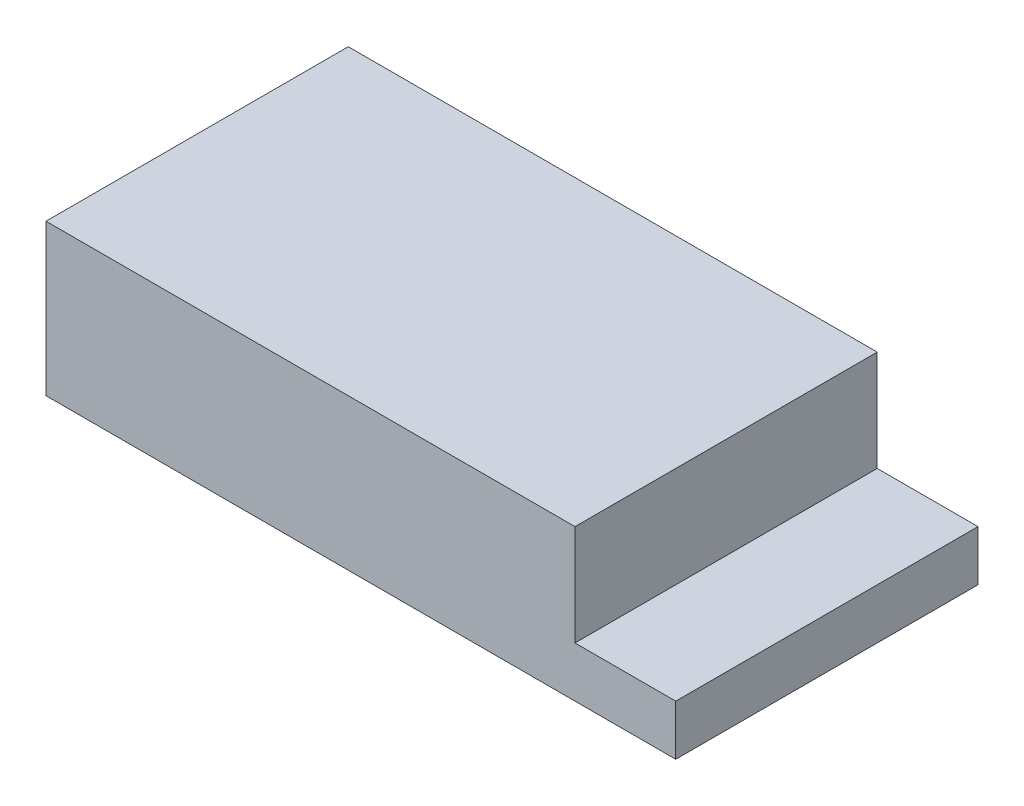
from build123d import *

# Parameters (mm, degrees)
SKETCH1_W           = 125
SKETCH1_H           = 60
BOSS_EXTRUDE1_DEPTH = 30
SKETCH2_W           = 20
SKETCH2_H           = 60
CUT_EXTRUDE1_DEPTH  = 20


with BuildPart() as part:
    # Sketch1 → Boss-Extrude1 (new body)
    with BuildSketch(Plane(origin=(0, 0, 0), x_dir=(1, 0, 0), z_dir=(0, 1, 0))):
        with Locations((62.5, 30)):
            Rectangle(SKETCH1_W, SKETCH1_H)
    extrude(amount=BOSS_EXTRUDE1_DEPTH)

    # Sketch2 → Cut-Extrude1 (cut)
    with BuildSketch(Plane(origin=(0, 30, 0), x_dir=(1, 0, 0), z_dir=(0, 1, 0))):
        with Locations((115, 30)):
            Rectangle(SKETCH2_W, SKETCH2_H)
    extrude(amount=-CUT_EXTRUDE1_DEPTH, mode=Mode.SUBTRACT)


solid = part.part
